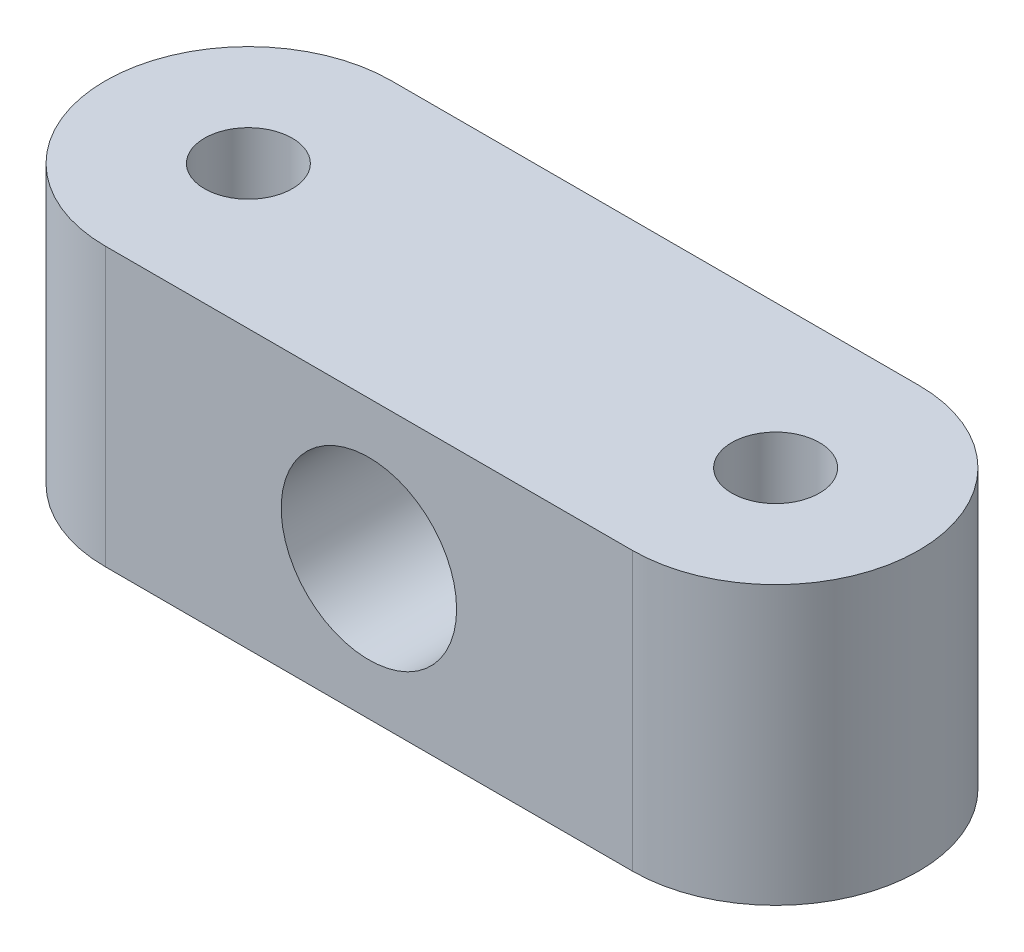
from build123d import *

# Parameters (mm, degrees)
SKETCH1_R           = 6
BOSS_EXTRUDE1_DEPTH = 38
SKETCH3_R           = 12
CUT_EXTRUDE2_DEPTH  = 98


with BuildPart() as part:
    # Sketch1 → Boss-Extrude1 (new body)
    with BuildSketch(Plane(origin=(0, 0, 0), x_dir=(1, 0, 0), z_dir=(0, 1, 0))):
        with BuildLine():
            Line((0, 19.577833845), (72.128861533, 19.577833845))
            ThreePointArc((72.128861533, 19.577833845), (91.706695377, 0), (72.128861533, -19.577833845))
            Line((72.128861533, -19.577833845), (0, -19.577833845))
            ThreePointArc((0, -19.577833845), (-19.577833845, 0), (0, 19.577833845))
        make_face()
        Circle(SKETCH1_R, mode=Mode.SUBTRACT)
        with Locations((72.128861533, 0)):
            Circle(SKETCH1_R, mode=Mode.SUBTRACT)
    extrude(amount=BOSS_EXTRUDE1_DEPTH)

    # Sketch3 → Cut-Extrude2 (cut)
    with BuildSketch(Plane.XY.offset(19.577833845)):
        with Locations((36.064430766, 19)):
            Circle(SKETCH3_R)
    extrude(amount=-CUT_EXTRUDE2_DEPTH, mode=Mode.SUBTRACT)


solid = part.part
